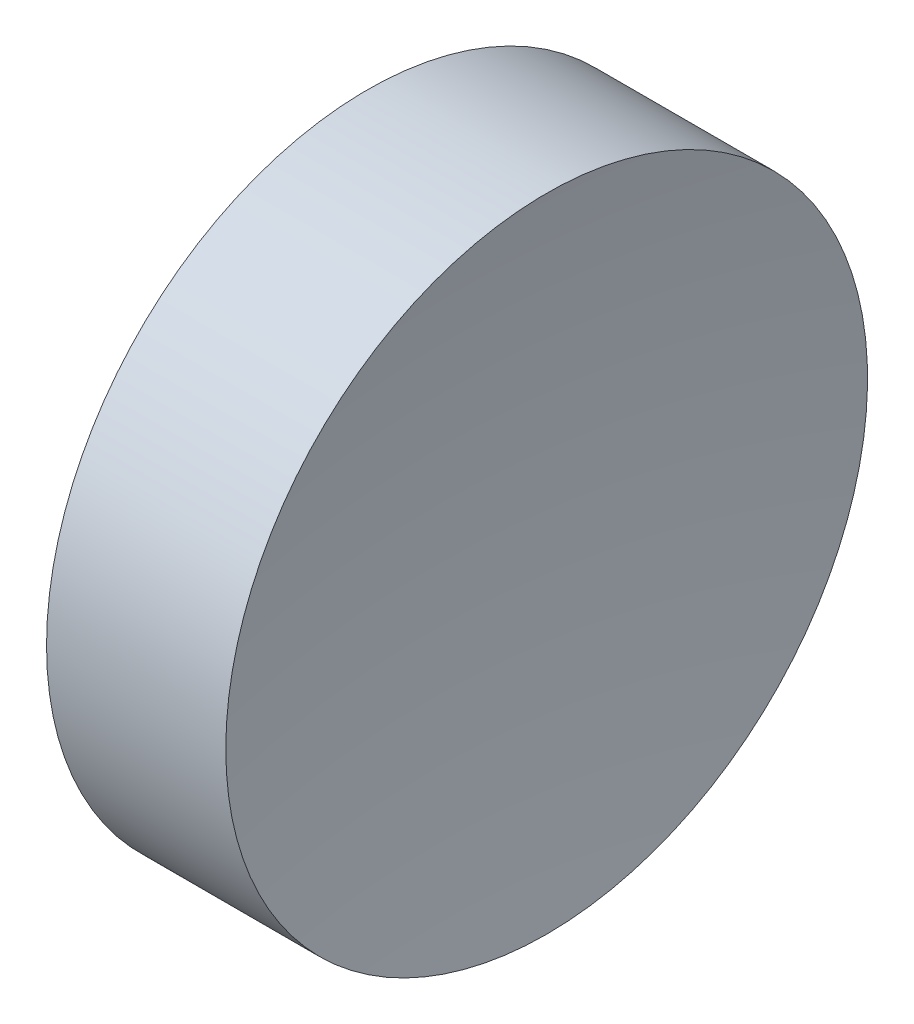
from build123d import *


with BuildPart() as part:
    # 草图1 → 旋转1 (revolve)
    with BuildSketch(Plane.XY, mode=Mode.PRIVATE) as revolve_1_sk:
        with BuildLine():
            Line((115.092655535, 69.378021123), (115.092655535, 81.878021123))
            Line((115.092655535, 81.878021123), (122.075266077, 81.878021123))
            ThreePointArc((122.075266077, 81.878021123), (121.338696747, 75.647301317), (121.092669224, 69.378021123))
            Line((121.092669224, 69.378021123), (115.092655535, 69.378021123))
        make_face()
    revolve(revolve_1_sk.sketch.rotate(Axis((108.985143002, 69.378021123, 0), (1, 0, 0)), 180), axis=Axis((108.985143002, 69.378021123, 0), (1, 0, 0)))  # turned: the seam where the file's is


solid = part.part
